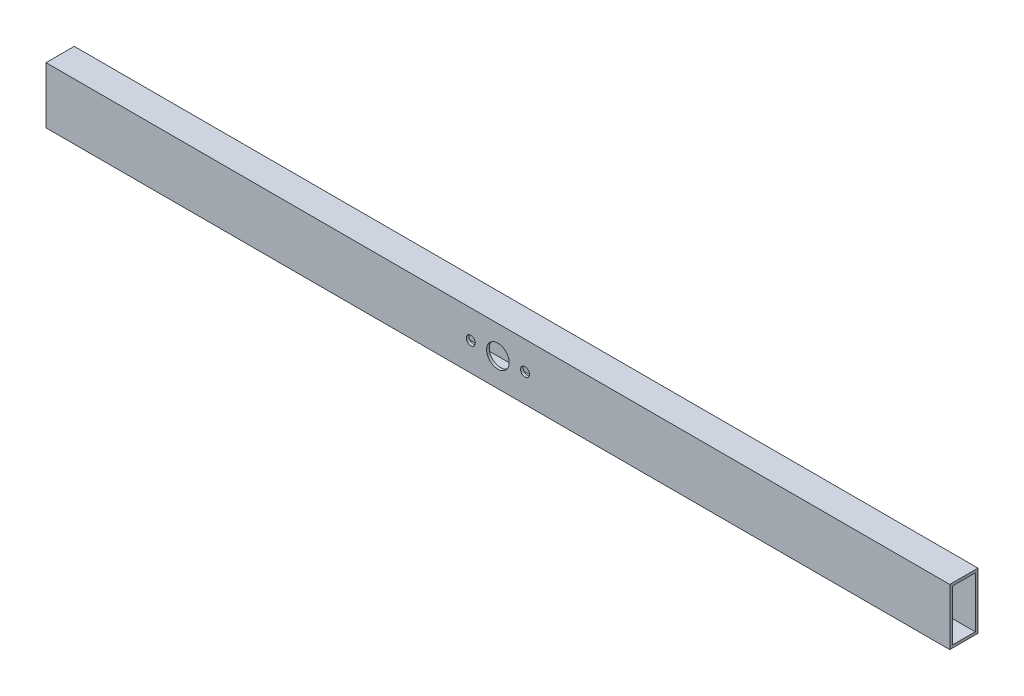
from build123d import *

# Parameters (mm, degrees)
SKETCH1_W           = 12.5
SKETCH1_H           = 25
SKETCH1_W_2         = 10.1
SKETCH1_H_2         = 22.6
BOSS_EXTRUDE1_DEPTH = 400
SKETCH3_R           = 5
SKETCH3_R_2         = 2
CUT_EXTRUDE1_DEPTH  = 20


with BuildPart() as part:
    # Sketch1 → Boss-Extrude1 (new body)
    with BuildSketch(Plane(origin=(0, 0, 0), x_dir=(0, 0, -1), z_dir=(1, 0, 0))):
        Rectangle(SKETCH1_W, SKETCH1_H)
        Rectangle(SKETCH1_W_2, SKETCH1_H_2, mode=Mode.SUBTRACT)
    extrude(amount=BOSS_EXTRUDE1_DEPTH)

    # Sketch3 → Cut-Extrude1 (cut)
    with BuildSketch(Plane(origin=(0, 0, -6.25), x_dir=(-1, 0, 0), z_dir=(0, 0, -1))):
        with Locations((-200, 0)):
            Circle(SKETCH3_R)
        with Locations((-188, 0)):
            Circle(SKETCH3_R_2)
        with Locations((-212, 0)):
            Circle(SKETCH3_R_2)
    extrude(amount=-CUT_EXTRUDE1_DEPTH, mode=Mode.SUBTRACT)


solid = part.part
